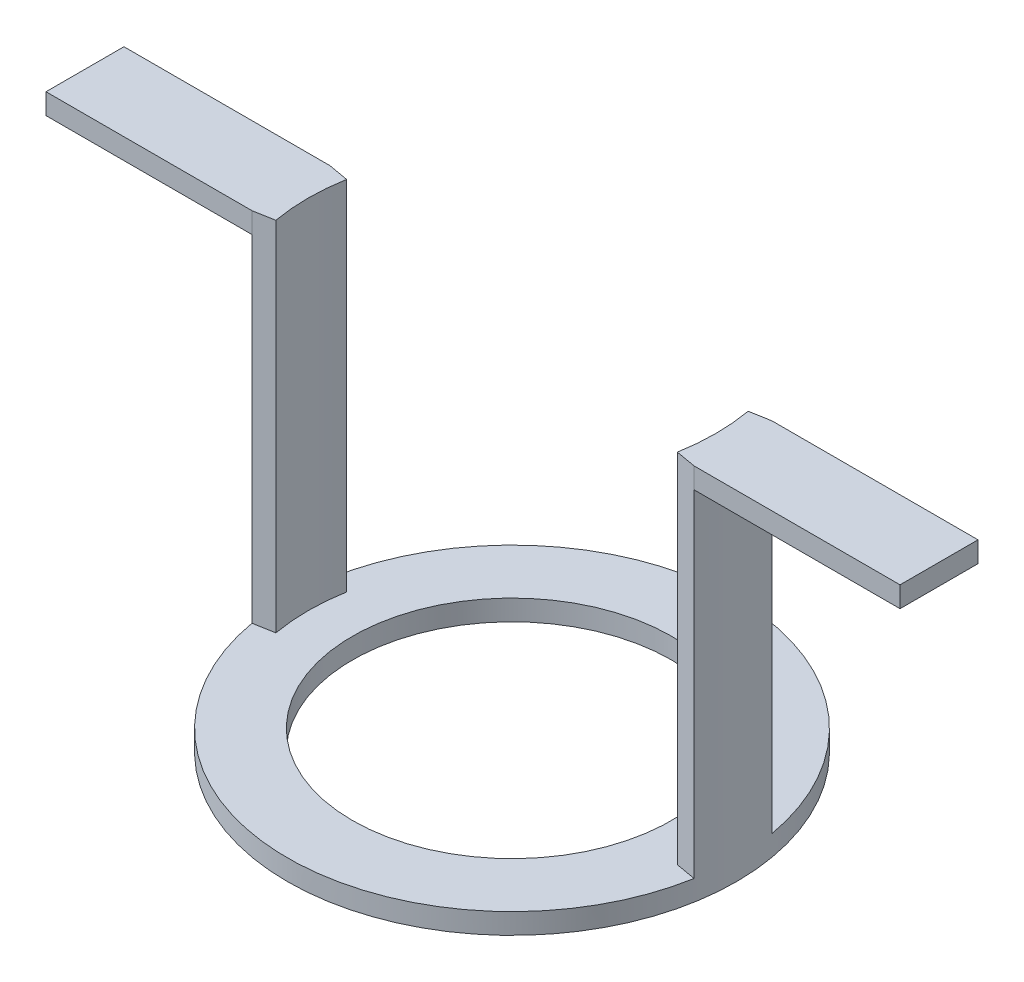
from build123d import *

# Parameters (mm, degrees)
SKETCH1_R           = 21.8
BOSS_EXTRUDE1_DEPTH = 2
SKETCH2_R           = 15.5
CUT_EXTRUDE1_DEPTH  = 16
BOSS_EXTRUDE2_DEPTH = 34.7
BOSS_EXTRUDE3_START = 21.468809
SKETCH4_W           = 7.571060546
SKETCH4_H           = 2.011077307
BOSS_EXTRUDE3_DEPTH = 13.531191
SKETCH5_W           = 7.571060546
SKETCH5_H           = 2.011077307
BOSS_EXTRUDE4_DEPTH = 3
SKETCH6_W           = 7.571060546
SKETCH6_H           = 2.011077307
BOSS_EXTRUDE5_DEPTH = 3.47
BOSS_EXTRUDE6_START = -35
SKETCH7_W           = 7.571060546
SKETCH7_H           = 2.011077307
BOSS_EXTRUDE6_DEPTH = 13.531191
SKETCH8_W           = 7.571060546
SKETCH8_H           = 2.011077307
BOSS_EXTRUDE7_DEPTH = 6.47


with BuildPart() as part:
    # Sketch1 → Boss-Extrude1 (new body)
    with BuildSketch(Plane(origin=(0, 0, 0), x_dir=(1, 0, 0), z_dir=(0, 1, 0))):
        Circle(SKETCH1_R)
    extrude(amount=BOSS_EXTRUDE1_DEPTH)

    # Sketch2 → Cut-Extrude1 (cut)
    with BuildSketch(Plane(origin=(0, 2, 0), x_dir=(1, 0, 0), z_dir=(0, 1, 0))):
        Circle(SKETCH2_R)
    extrude(amount=-CUT_EXTRUDE1_DEPTH, mode=Mode.SUBTRACT)

    # Sketch3 → Boss-Extrude2 (add)
    with BuildSketch(Plane(origin=(0, 2, 0), x_dir=(1, 0, 0), z_dir=(0, 1, 0))):
        with BuildLine():
            Line((-19.499166961, 3.438229237), (-21.468809016, 3.785530273))
            ThreePointArc((-21.468809016, 3.785530273), (-21.717044418, 1.899995192), (-21.8, 0))
            ThreePointArc((-21.8, 0), (-21.717044418, -1.899995192), (-21.468809016, -3.785530273))
            Line((-21.468809016, -3.785530273), (-19.499166961, -3.438229237))
            ThreePointArc((-19.499166961, -3.438229237), (-19.724628167, -1.725681357), (-19.799973042, 0))
            ThreePointArc((-19.799973042, 0), (-19.724628167, 1.725681357), (-19.499166961, 3.438229237))
        make_face()
        with BuildLine():
            Line((21.468809016, -3.785530273), (19.499001497, -3.438200061))
            ThreePointArc((19.499001497, -3.438200061), (19.72446079, -1.725666713), (19.799805025, 0))
            ThreePointArc((19.799805025, 0), (19.72446079, 1.725666713), (19.499001497, 3.438200061))
            Line((19.499001497, 3.438200061), (21.468809016, 3.785530273))
            ThreePointArc((21.468809016, 3.785530273), (21.717044418, 1.899995192), (21.8, 0))
            ThreePointArc((21.8, 0), (21.717044418, -1.899995192), (21.468809016, -3.785530273))
        make_face()
    extrude(amount=BOSS_EXTRUDE2_DEPTH)

    # Sketch4 → Boss-Extrude3 (add)
    with BuildSketch(Plane(origin=(0, 0, 0), x_dir=(0, 0, -1), z_dir=(1, 0, 0)).offset(BOSS_EXTRUDE3_START)):
        with Locations((0, 35.694461347)):
            Rectangle(SKETCH4_W, SKETCH4_H)
    extrude(amount=BOSS_EXTRUDE3_DEPTH)

    # Sketch5 → Boss-Extrude4 (add)
    with BuildSketch(Plane(origin=(35, 0, 0), x_dir=(0, 0, -1), z_dir=(1, 0, 0))):
        with Locations((0, 35.694461347)):
            Rectangle(SKETCH5_W, SKETCH5_H)
    extrude(amount=BOSS_EXTRUDE4_DEPTH)

    # Sketch6 → Boss-Extrude5 (add)
    with BuildSketch(Plane(origin=(38, 0, 0), x_dir=(0, 0, -1), z_dir=(1, 0, 0))):
        with Locations((0, 35.694461347)):
            Rectangle(SKETCH6_W, SKETCH6_H)
    extrude(amount=BOSS_EXTRUDE5_DEPTH)

    # Sketch7 → Boss-Extrude6 (add)
    with BuildSketch(Plane(origin=(0, 0, 0), x_dir=(0, 0, -1), z_dir=(1, 0, 0)).offset(BOSS_EXTRUDE6_START)):
        with Locations((0, 35.694461347)):
            Rectangle(SKETCH7_W, SKETCH7_H)
    extrude(amount=BOSS_EXTRUDE6_DEPTH)

    # Sketch8 → Boss-Extrude7 (add)
    with BuildSketch(Plane(origin=(-35, 34.688922693, 3.785530273), x_dir=(0, 0, 1), z_dir=(-1, 0, 0))):
        with Locations((-3.785530273, 1.005538654)):
            Rectangle(SKETCH8_W, SKETCH8_H)
    extrude(amount=BOSS_EXTRUDE7_DEPTH)


solid = part.part
